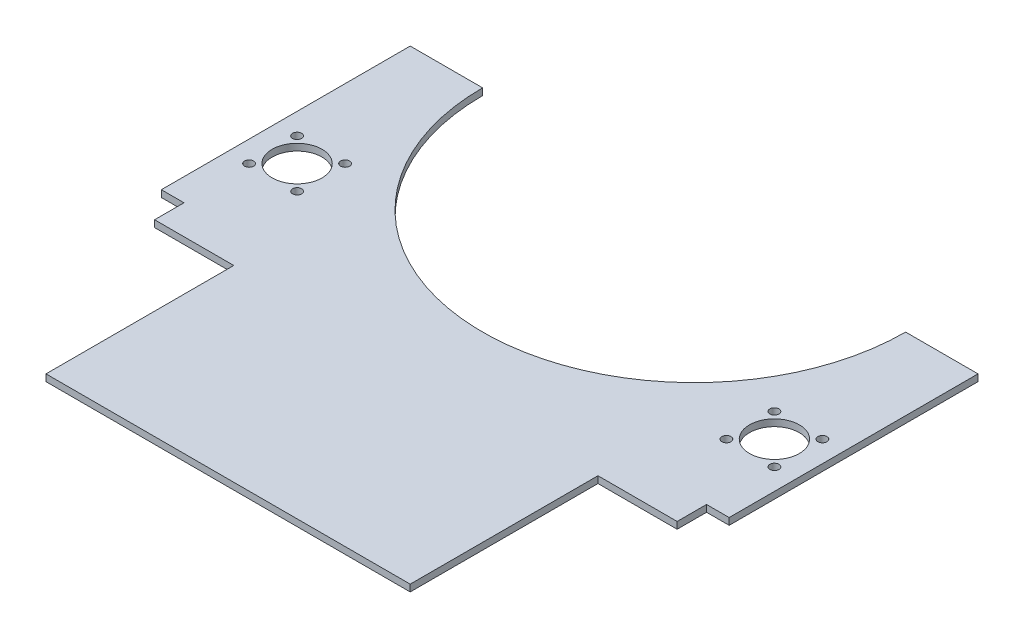
from build123d import *

# Parameters (mm, degrees)
ESQUISSE1_R      = 2
ESQUISSE1_R_2    = 11
EXTRUSION1_DEPTH = 3


with BuildPart() as part:
    # Esquisse1 → Extrusion1 (new body)
    with BuildSketch(Plane(origin=(0, 0, 0), x_dir=(1, 0, 0), z_dir=(0, 1, 0))):
        with BuildLine():
            Line((80.5, 0), (-80.5, 0))
            Line((-80.5, 0), (-80.5, 83))
            Line((-80.5, 83), (-115.5, 83))
            Line((-115.5, 83), (-115.5, 96))
            Line((-115.5, 96), (-125.5, 96))
            Line((-125.5, 96), (-125.5, 206))
            Line((-125.5, 206), (-93.5, 206))
            ThreePointArc((-93.5, 206), (0, 112.5), (93.5, 206))
            Line((93.5, 206), (125.5, 206))
            Line((125.5, 206), (125.5, 96))
            Line((125.5, 96), (115.5, 96))
            Line((115.5, 96), (115.5, 83))
            Line((115.5, 83), (80.5, 83))
            Line((80.5, 83), (80.5, 0))
        make_face()
        with Locations((94.89, 146.61)):
            Circle(ESQUISSE1_R, mode=Mode.SUBTRACT)
        with Locations((-105.5, 136)):
            Circle(ESQUISSE1_R_2, mode=Mode.SUBTRACT)
        with Locations((-116.11, 146.61)):
            Circle(ESQUISSE1_R, mode=Mode.SUBTRACT)
        with Locations((-116.11, 125.39)):
            Circle(ESQUISSE1_R, mode=Mode.SUBTRACT)
        with Locations((-94.89, 125.39)):
            Circle(ESQUISSE1_R, mode=Mode.SUBTRACT)
        with Locations((-94.89, 146.61)):
            Circle(ESQUISSE1_R, mode=Mode.SUBTRACT)
        with Locations((94.89, 125.39)):
            Circle(ESQUISSE1_R, mode=Mode.SUBTRACT)
        with Locations((116.11, 125.39)):
            Circle(ESQUISSE1_R, mode=Mode.SUBTRACT)
        with Locations((116.11, 146.61)):
            Circle(ESQUISSE1_R, mode=Mode.SUBTRACT)
        with Locations((105.5, 136)):
            Circle(ESQUISSE1_R_2, mode=Mode.SUBTRACT)
    extrude(amount=EXTRUSION1_DEPTH)


solid = part.part
